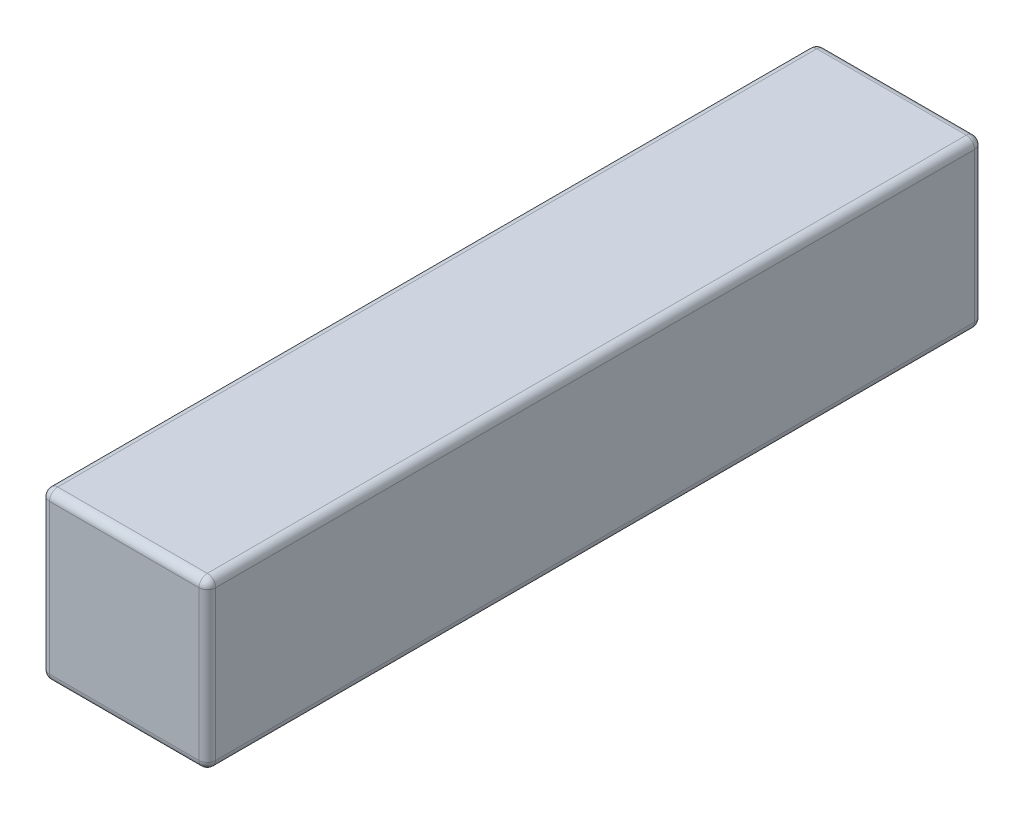
from build123d import *

# Parameters (mm, degrees)
SKETCH3_W                = 3
SKETCH3_H                = 3
BOSS_EXTRUDE1_DEPTH      = 7
BOSS_EXTRUDE1_DEPTH_BACK = 7
FILLET2_R                = 0.15


with BuildPart() as part:
    # Sketch3 → Boss-Extrude1 (new body, two sides)
    with BuildSketch(Plane.XY) as boss_extrude1_sk:
        Rectangle(SKETCH3_W, SKETCH3_H)
    extrude(amount=BOSS_EXTRUDE1_DEPTH)
    extrude(boss_extrude1_sk.sketch, amount=-BOSS_EXTRUDE1_DEPTH_BACK)

    # Fillet2
    fillet2_edges = [part.edges().sort_by_distance(p)[0] for p in [
        (0, 1.5, 7),
        (0, -1.5, -7),
        (-1.5, 0, -7),
        (0, 1.5, -7),
        (1.5, 0, -7),
        (-1.5, 0, 7),
        (0, -1.5, 7),
        (1.5, 0, 7),
        (-1.5, -1.5, 0),
        (-1.5, 1.5, 0),
        (1.5, 1.5, 0),
        (1.5, -1.5, 0),
    ]]
    fillet(fillet2_edges, radius=FILLET2_R)


solid = part.part
